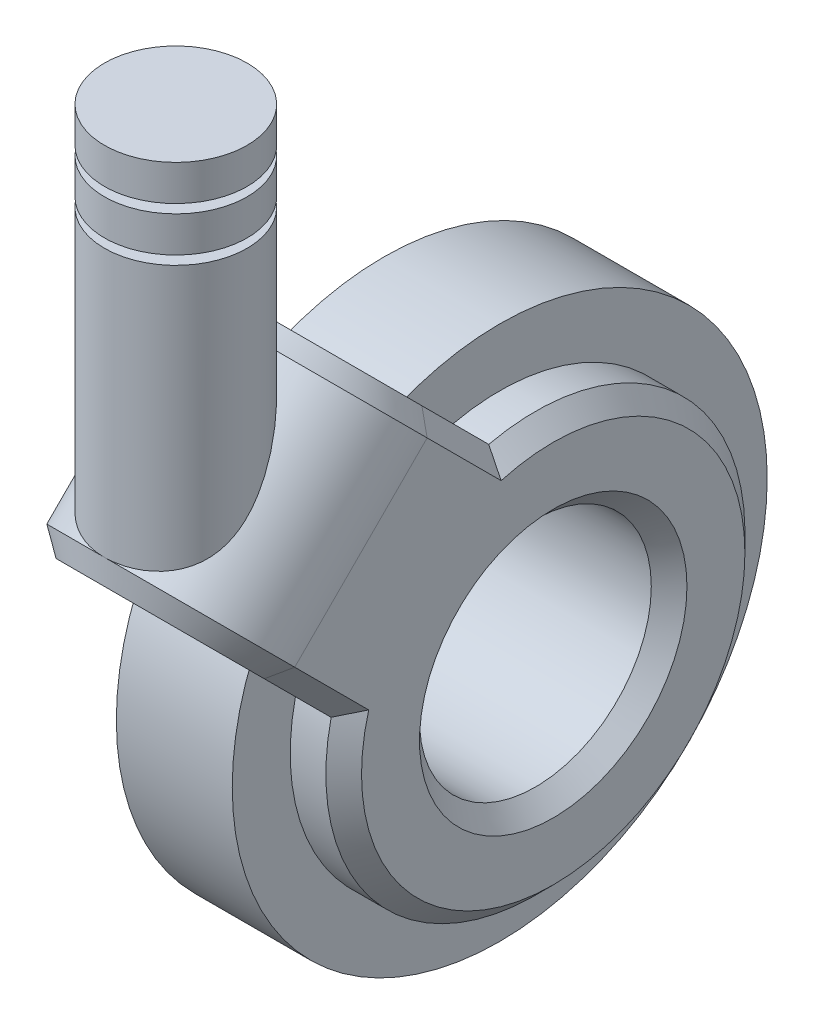
from build123d import *

# Parameters (mm, degrees)
SKETCH1_R           = 30
SKETCH1_R_2         = 13.5
BOSS_EXTRUDE1_DEPTH = 6.5
SKETCH2_R           = 23.5
SKETCH2_R_2         = 13
BOSS_EXTRUDE2_DEPTH = 12.5
BOSS_EXTRUDE3_DEPTH = 12.5
CHAMFER1_SIZE       = 2
BOSS_EXTRUDE4_REACH = 94.067
SKETCH5_R           = 8


with BuildPart() as part:
    # Sketch1 → Boss-Extrude1 (new, symmetric)
    with BuildSketch(Plane(origin=(0, 0, 0), x_dir=(0, 0, -1), z_dir=(1, 0, 0))):
        with Locations(Location((0, 0, 0), (0, 0, 180))):
            Circle(SKETCH1_R)
        with Locations(Location((0, 0, 0), (0, 0, 180))):
            Circle(SKETCH1_R_2, mode=Mode.SUBTRACT)
    extrude(amount=BOSS_EXTRUDE1_DEPTH, both=True)


with BuildPart() as body_2:
    # Sketch2 → Boss-Extrude2 (new, symmetric)
    with BuildSketch(Plane(origin=(0, 0, 0), x_dir=(0, 0, -1), z_dir=(1, 0, 0))):
        Circle(SKETCH2_R)
        Circle(SKETCH2_R_2, mode=Mode.SUBTRACT)
    extrude(amount=BOSS_EXTRUDE2_DEPTH, both=True)

    # Sketch4 → Boss-Extrude3 (add, symmetric)
    with BuildSketch(Plane(origin=(0, 0, 0), x_dir=(-1, 0, 0), z_dir=(0, 0.7071067811865475, -0.7071067811865477))):
        with BuildLine():
            Line((-12.5, 18.5), (-12.5, 30.5))
            ThreePointArc((-12.5, 30.5), (0, 43), (12.5, 30.5))
            Line((12.5, 30.5), (12.5, 18.5))
            Line((12.5, 18.5), (7.5, 18.5))
            Line((7.5, 18.5), (7.5, 30.5))
            ThreePointArc((7.5, 30.5), (0, 38), (-7.5, 30.5))
            Line((-7.5, 30.5), (-7.5, 18.5))
            Line((-7.5, 18.5), (-12.5, 18.5))
        make_face()
    extrude(amount=BOSS_EXTRUDE3_DEPTH, both=True)

    # Chamfer1
    chamfer1_edges = [body_2.edges().sort_by_distance(p)[0] for p in [
        (12.5, -23.352054814, 2.632781035),
        (-12.5, -23.352054814, 2.632781035),
        (-12.5, 26.657836818, 8.980167288),
        (0, 39.244426356, 21.566756826),
        (12.5, 26.657836818, 8.980167288),
        (-12.5, 8.980167288, 26.657836818),
        (0, 21.566756826, 39.244426356),
        (12.5, 8.980167288, 26.657836818),
        (-12.5, 0, 13),
        (12.5, 0, 13),
    ]]
    chamfer(chamfer1_edges, length=CHAMFER1_SIZE)

    # Sketch5 → Boss-Extrude4 (add, up to next)
    with BuildSketch(Plane(origin=(0, 53, 0), x_dir=(1, 0, 0), z_dir=(0, 1, 0)), mode=Mode.PRIVATE) as boss_extrude4_sk1:
        with Locations(Location((0, -29.830212793, 0), (0, 0, 270))):
            Circle(SKETCH5_R)
    boss_extrude4_tool1 = extrude(boss_extrude4_sk1.sketch, amount=-BOSS_EXTRUDE4_REACH, mode=Mode.PRIVATE) - body_2.part
    add(boss_extrude4_tool1.solids().sort_by_distance((0, 53, 29.830213))[0])

    # Sketch6 → Revolve1 (revolve)
    with BuildSketch(Plane(origin=(0, 0, 0), x_dir=(0, 0, -1), z_dir=(1, 0, 0))):
        Polygon((-29.830212793, 53), (-29.830212793, 63), (-21.830212793, 63), (-21.830212793, 59), (-23.830212793, 59), (-23.830212793, 58), (-21.830212793, 58), (-21.830212793, 54), (-23.830212793, 54), (-23.830212793, 53), align=None)
    revolve(axis=Axis((0, 53, 29.830212793), (0, 1, 0)))


solid = Compound([part.part, body_2.part])
